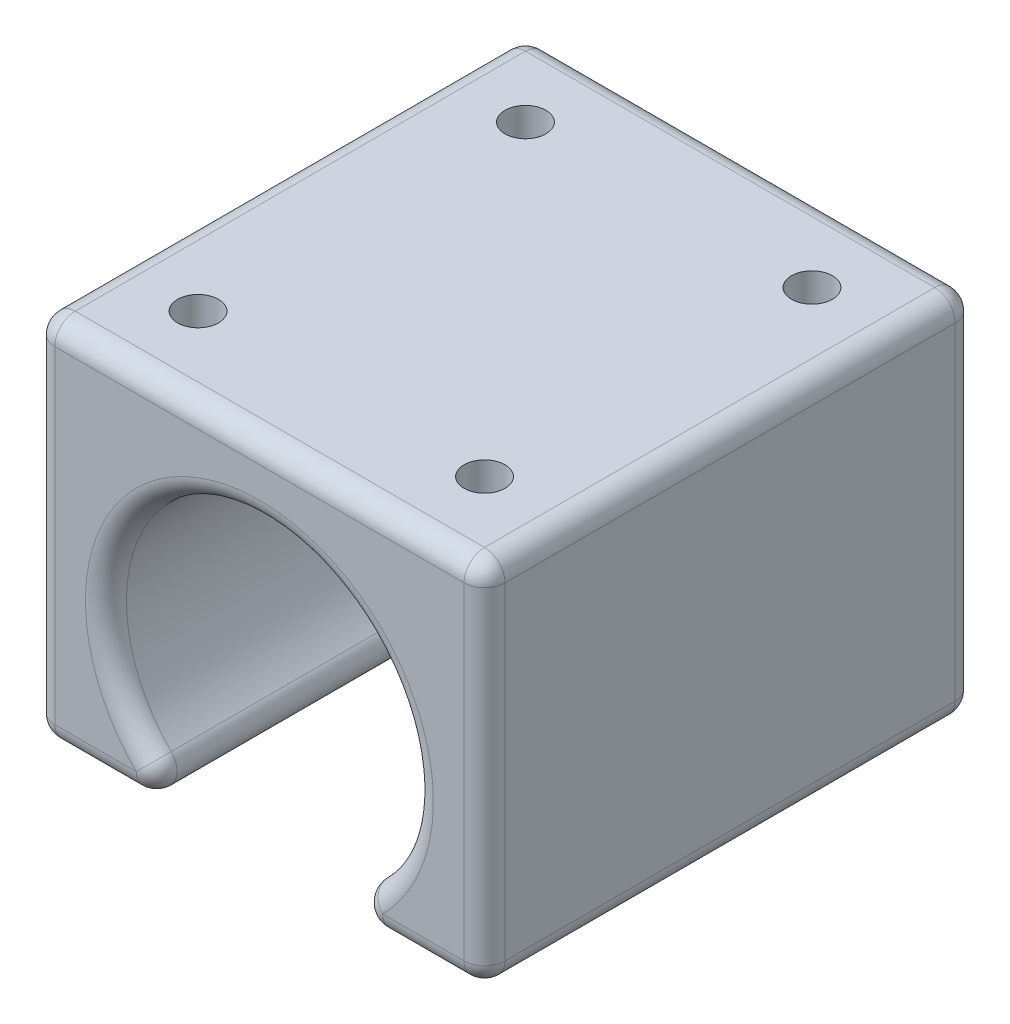
from build123d import *

# Parameters (mm, degrees)
BOSS_EXTRU_1_DEPTH      = 12
BOSS_EXTRU_1_DEPTH_BACK = 12
ENL_V_START             = 9
ESQUISSE2_R             = 1
ENL_V_MAT_EXTRU_1_DEPTH = 4
CONG_1_R                = 1


with BuildPart() as part:
    # Esquisse1 → Boss.-Extru.1 (new body, two sides)
    with BuildSketch(Plane.XY) as boss_extru_1_sk:
        with BuildLine():
            Line((11, -9), (2.692582404, -9))
            ThreePointArc((2.692582404, -9), (0, 5.5), (-2.692582404, -9))
            Line((-2.692582404, -9), (-11, -9))
            Line((-11, -9), (-11, 9))
            Line((-11, 9), (11, 9))
            Line((11, 9), (11, -9))
        make_face()
    extrude(amount=BOSS_EXTRU_1_DEPTH)
    extrude(boss_extru_1_sk.sketch, amount=-BOSS_EXTRU_1_DEPTH_BACK)

    # Esquisse2 → Enl_v. mat.-Extru.1 (cut)
    with BuildSketch(Plane(origin=(0, 0, 0), x_dir=(1, 0, 0), z_dir=(0, 1, 0)).offset(ENL_V_START)):
        with Locations((-7, 8)):
            Circle(ESQUISSE2_R)
        with Locations((7, 8)):
            Circle(ESQUISSE2_R)
        with Locations((7, -8)):
            Circle(ESQUISSE2_R)
        with Locations((-7, -8)):
            Circle(ESQUISSE2_R)
    extrude(amount=-ENL_V_MAT_EXTRU_1_DEPTH, mode=Mode.SUBTRACT)

    # Cong_1
    cong_1_edges = [part.edges().sort_by_distance(p)[0] for p in [
        (-11, 9, 0),
        (11, 9, 0),
        (11, -9, 0),
        (2.692582404, -9, 0),
        (-2.692582404, -9, 0),
        (-11, -9, 0),
        (0, 5.5, -12),
        (6.846291202, -9, -12),
        (-11, 0, 12),
        (-6.846291202, -9, 12),
        (0, 5.5, 12),
        (6.846291202, -9, 12),
        (11, 0, 12),
        (0, 9, 12),
        (11, 0, -12),
        (0, 9, -12),
        (-11, 0, -12),
        (-6.846291202, -9, -12),
    ]]
    fillet(cong_1_edges, radius=CONG_1_R)


solid = part.part
